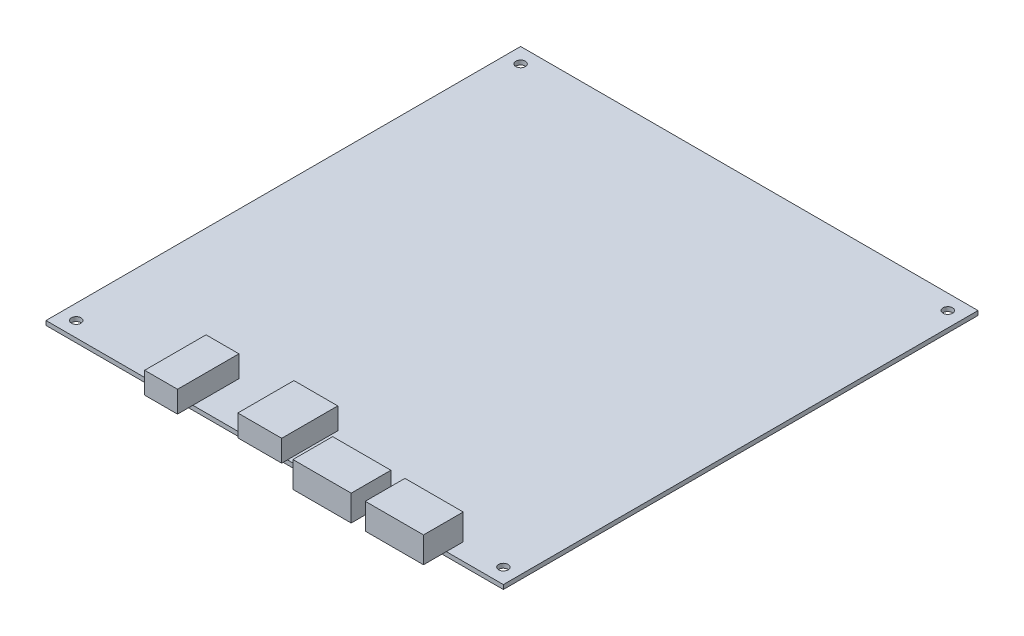
from build123d import *

# Parameters (mm, degrees)
SKETCH1_W           = 106
SKETCH1_H           = 110
SKETCH1_R           = 1.1
BOSS_EXTRUDE1_DEPTH = 1
BOSS_EXTRUDE3_DEPTH = 5
SKETCH3_W           = 10.16
SKETCH3_H           = 13
BOSS_EXTRUDE4_DEPTH = 5
SKETCH4_W           = 13.5
SKETCH4_H           = 9.2
BOSS_EXTRUDE5_DEPTH = 6


with BuildPart() as part:
    # Sketch1 → Boss-Extrude1 (new body)
    with BuildSketch(Plane(origin=(0, 0, 0), x_dir=(1, 0, 0), z_dir=(0, 1, 0))):
        with Locations((8.955727632, 44.943820005)):
            Rectangle(SKETCH1_W, SKETCH1_H)
        with Locations(Location((-40.544272368, -6.556179995, 0), (0, 0, 270))):
            Circle(SKETCH1_R, mode=Mode.SUBTRACT)
        with Locations(Location((58.455727632, -6.556179995, 0), (0, 0, 270))):
            Circle(SKETCH1_R, mode=Mode.SUBTRACT)
        with Locations(Location((-40.544272368, 96.443820005, 0), (0, 0, 270))):
            Circle(SKETCH1_R, mode=Mode.SUBTRACT)
        with Locations(Location((58.455727632, 96.443820005, 0), (0, 0, 270))):
            Circle(SKETCH1_R, mode=Mode.SUBTRACT)
    extrude(amount=BOSS_EXTRUDE1_DEPTH)

    # 3DSketch1 → Boss-Extrude3 (add)
    with BuildSketch(Plane(origin=(-17.624272368, 1, -0.613820005), x_dir=(0.47206668121683765, 0, 0.8815628443196325), z_dir=(0, -1, 0))):
        Polygon((0, 0), (3.597148111, -6.717508874), (16.141787386, 0), (12.544639275, 6.717508874), align=None)
    extrude(amount=-BOSS_EXTRUDE3_DEPTH)

    # Sketch3 → Boss-Extrude4 (add)
    with BuildSketch(Plane(origin=(0, 1, 0), x_dir=(1, 0, 0), z_dir=(0, 1, 0))):
        with Locations((6.825727632, -4.886179995)):
            Rectangle(SKETCH3_W, SKETCH3_H)
    extrude(amount=BOSS_EXTRUDE4_DEPTH)

    # Sketch4 → Boss-Extrude5 (add)
    with BuildSketch(Plane(origin=(0, 1, 0), x_dir=(-1, 0, 0), z_dir=(0, 1, 0))):
        with Locations((-41.985727632, 10.746179995)):
            Rectangle(SKETCH4_W, SKETCH4_H)
        with Locations((-25.225727632, 10.746179995)):
            Rectangle(SKETCH4_W, SKETCH4_H)
    extrude(amount=BOSS_EXTRUDE5_DEPTH)


solid = part.part
